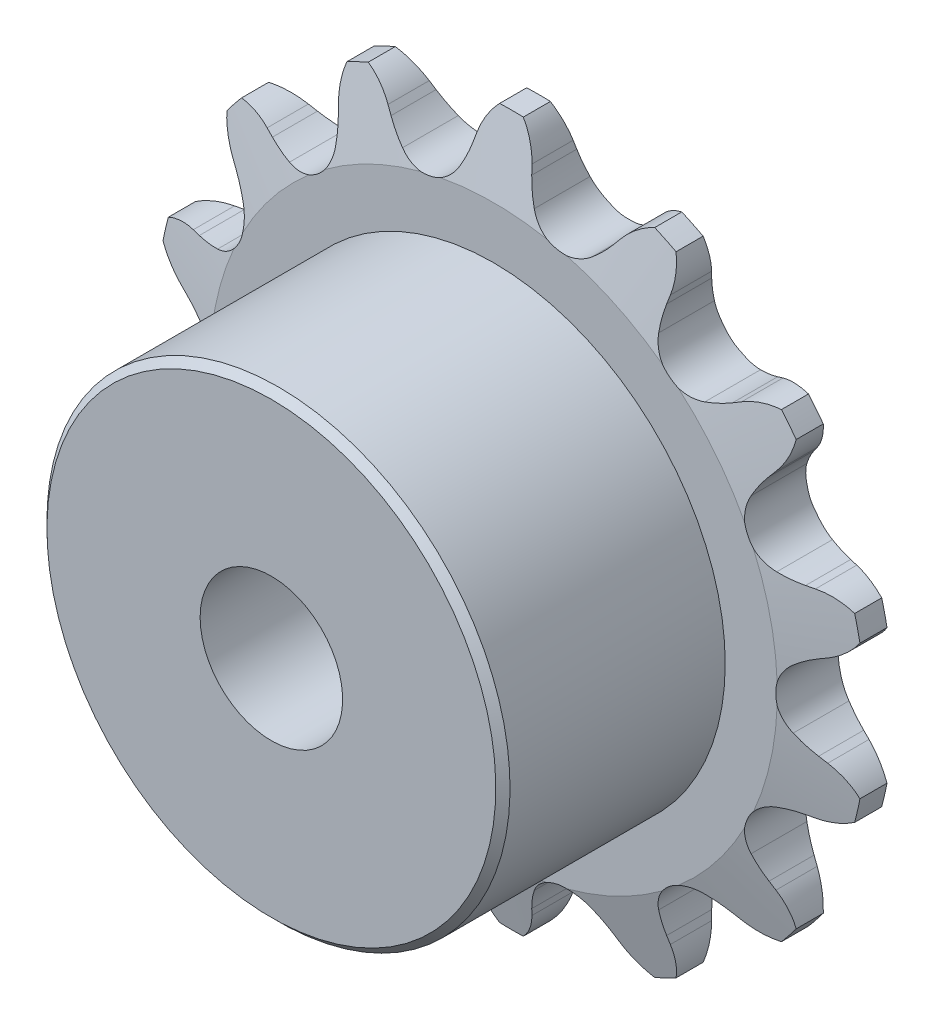
from build123d import *

# Parameters (mm, degrees)
CUT_EXTRUDE1_DEPTH      = 23.410198508
CIRPATTERN1_COUNT       = 14
BOSS_EXTRUDE1_START     = 1.397
SKETCH2_R               = 10.31875
BOSS_EXTRUDE1_DEPTH     = 9.906
CUT_EXTRUDE2_DEPTH      = 25.879893202
CUT_EXTRUDE2_DEPTH_BACK = 25.879893202
SKETCH3_R               = 3.175
SKETCH4_W               = 2.0955
SKETCH4_H               = 5.461


with BuildPart() as part:
    # Sketch1 → Revolve1 (revolve)
    with BuildSketch(Plane(origin=(0, 0, 0), x_dir=(0, 0, -1), z_dir=(1, 0, 0)), mode=Mode.PRIVATE) as revolve1_sk:
        Polygon((1.397, 0), (-1.397, 0), (-1.397, 12.640583899), (-0.60325, 15.815583899), (0.60325, 15.815583899), (1.397, 12.640583899), align=None)
    revolve(revolve1_sk.sketch.rotate(Axis((0, 0, -1.397), (0, 0, 1)), 90), axis=Axis((0, 0, -1.397), (0, 0, 1)))

    # Sketch0 → Cut-Extrude1 (cut, symmetric)
    with BuildSketch(Plane.XY):
        with BuildLine():
            Line((5.186129219, -13.596278832), (4.966335914, -13.31639744))
            ThreePointArc((4.966335914, -13.31639744), (4.614309016, -12.92049686), (4.216657928, -12.570448549))
            ThreePointArc((4.216657928, -12.570448549), (2.79730298, -12.255785133), (1.655035699, -13.155122107))
            ThreePointArc((1.655035699, -13.155122107), (1.448644719, -13.643039078), (1.303254266, -14.152471922))
            Line((1.303254266, -14.152471922), (1.226663327, -14.500001084))
            ThreePointArc((1.226663327, -14.500001084), (0.154762783, -16.131385383), (-1.73130393, -16.634513455))
            ThreePointArc((-1.73130393, -16.634513455), (3.721521762, -16.305052191), (8.777295839, -14.235994133))
            ThreePointArc((8.777295839, -14.235994133), (6.859709357, -14.601025081), (5.186129219, -13.596278832))
        make_face()
    cut_extrude1 = extrude(amount=CUT_EXTRUDE1_DEPTH, both=True, mode=Mode.SUBTRACT)

    # CirPattern1: Cut-Extrude1 ×14 about axis
    cirpattern1_axis = Axis((0, 0, 0), (0, 0, 1))
    for i in range(1, CIRPATTERN1_COUNT):
        add(cut_extrude1.rotate(cirpattern1_axis, i * 360 / CIRPATTERN1_COUNT), mode=Mode.SUBTRACT)

    # Sketch2 → Boss-Extrude1 (add)
    with BuildSketch(Plane.XY.offset(BOSS_EXTRUDE1_START)):
        Circle(SKETCH2_R)
    extrude(amount=BOSS_EXTRUDE1_DEPTH)

    # Sketch3 → Cut-Extrude2 (cut, two sides: drawn at the far end of the back side and taken through both)
    with BuildSketch(Plane.XY.offset(-CUT_EXTRUDE2_DEPTH_BACK)):
        with Locations(Location((0, 0, 0), (0, 0, 180))):
            Circle(SKETCH3_R)
    extrude(amount=CUT_EXTRUDE2_DEPTH + CUT_EXTRUDE2_DEPTH_BACK, mode=Mode.SUBTRACT)

    # Sketch4 → Cut-Revolve1 (revolve, cut)
    with BuildSketch(Plane(origin=(0, 0, 0), x_dir=(0, 0, -1), z_dir=(1, 0, 0))):
        Polygon((-11.303, 10.31875), (-11.303, 10.00125), (-10.9855, 10.31875), align=None)
        with Locations((-2.44475, 13.085083899)):
            Rectangle(SKETCH4_W, SKETCH4_H)
    revolve(axis=Axis((0, 0, -1.397), (0, 0, 1)), mode=Mode.SUBTRACT)


solid = part.part
